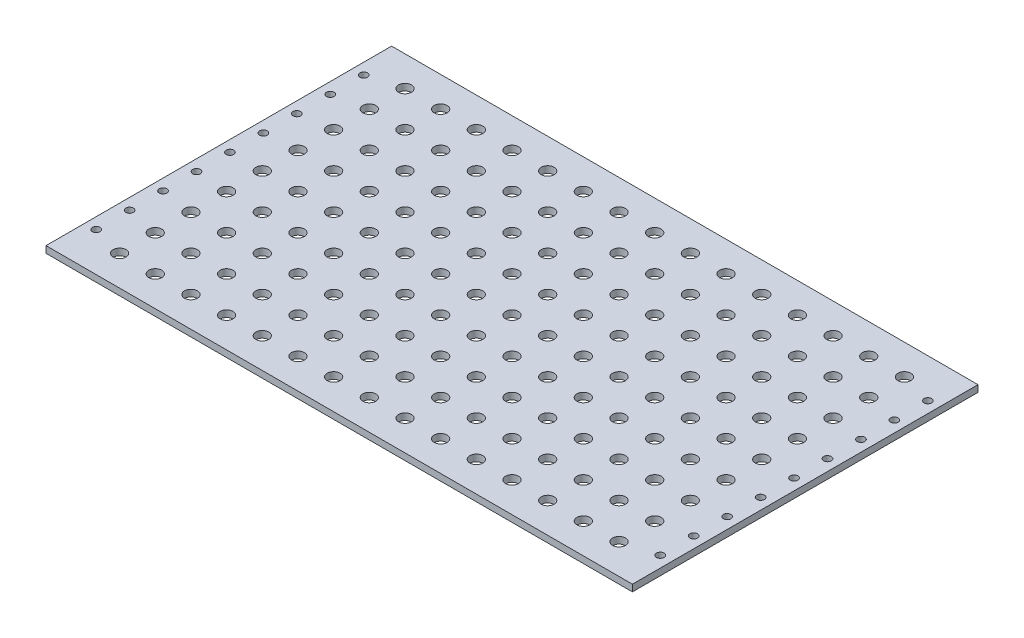
from build123d import *

# Parameters (mm, degrees)
CROQUIS1_W                   = 263
CROQUIS1_H                   = 155
SALIENTE_EXTRUIR1_DEPTH      = 3
TALADRO_DE_MARGEN_PARA_M51_D = 5.8
MATRIZL1_COUNT               = 8
MATRIZL1_PITCH               = 16
MATRIZL1_COUNT_DIR2          = 5
MATRIZL1_PITCH_DIR2          = 16
SIMETR_A1_COPY_1_D           = 5.8
SIMETR_A1_COPY_2_D           = 5.8
SIMETR_A1_COPY_3_D           = 5.8
SIMETR_A1_COPY_4_D           = 5.8
SIMETR_A1_COPY_5_D           = 5.8
SIMETR_A1_COPY_6_D           = 5.8
SIMETR_A1_COPY_7_D           = 5.8
SIMETR_A1_COPY_8_D           = 5.8
SIMETR_A1_COPY_9_D           = 5.8
SIMETR_A1_COPY_10_D          = 5.8
SIMETR_A1_COPY_11_D          = 5.8
SIMETR_A1_COPY_12_D          = 5.8
SIMETR_A1_COPY_13_D          = 5.8
SIMETR_A1_COPY_14_D          = 5.8
SIMETR_A1_COPY_15_D          = 5.8
SIMETR_A1_COPY_16_D          = 5.8
SIMETR_A1_COPY_17_D          = 5.8
SIMETR_A1_COPY_18_D          = 5.8
SIMETR_A1_COPY_19_D          = 5.8
SIMETR_A1_COPY_20_D          = 5.8
SIMETR_A1_COPY_21_D          = 5.8
SIMETR_A1_COPY_22_D          = 5.8
SIMETR_A1_COPY_23_D          = 5.8
SIMETR_A1_COPY_24_D          = 5.8
SIMETR_A1_COPY_25_D          = 5.8
SIMETR_A1_COPY_26_D          = 5.8
SIMETR_A1_COPY_27_D          = 5.8
SIMETR_A1_COPY_28_D          = 5.8
SIMETR_A1_COPY_29_D          = 5.8
SIMETR_A1_COPY_30_D          = 5.8
SIMETR_A1_COPY_31_D          = 5.8
SIMETR_A1_COPY_32_D          = 5.8
SIMETR_A1_COPY_33_D          = 5.8
SIMETR_A1_COPY_34_D          = 5.8
SIMETR_A1_COPY_35_D          = 5.8
SIMETR_A1_COPY_36_D          = 5.8
SIMETR_A1_COPY_37_D          = 5.8
SIMETR_A1_COPY_38_D          = 5.8
SIMETR_A1_COPY_39_D          = 5.8
SIMETR_A1_COPY_40_D          = 5.8
SIMETR_A2_COPY_1_D           = 5.8
SIMETR_A2_COPY_2_D           = 5.8
SIMETR_A2_COPY_3_D           = 5.8
SIMETR_A2_COPY_4_D           = 5.8
SIMETR_A2_COPY_5_D           = 5.8
SIMETR_A2_COPY_6_D           = 5.8
SIMETR_A2_COPY_7_D           = 5.8
SIMETR_A2_COPY_8_D           = 5.8
SIMETR_A2_COPY_9_D           = 5.8
SIMETR_A2_COPY_10_D          = 5.8
SIMETR_A2_COPY_11_D          = 5.8
SIMETR_A2_COPY_12_D          = 5.8
SIMETR_A2_COPY_13_D          = 5.8
SIMETR_A2_COPY_14_D          = 5.8
SIMETR_A2_COPY_15_D          = 5.8
SIMETR_A2_COPY_16_D          = 5.8
SIMETR_A2_COPY_17_D          = 5.8
SIMETR_A2_COPY_18_D          = 5.8
SIMETR_A2_COPY_19_D          = 5.8
SIMETR_A2_COPY_20_D          = 5.8
SIMETR_A2_COPY_21_D          = 5.8
SIMETR_A2_COPY_22_D          = 5.8
SIMETR_A2_COPY_23_D          = 5.8
SIMETR_A2_COPY_24_D          = 5.8
SIMETR_A2_COPY_25_D          = 5.8
SIMETR_A2_COPY_26_D          = 5.8
SIMETR_A2_COPY_27_D          = 5.8
SIMETR_A2_COPY_28_D          = 5.8
SIMETR_A2_COPY_29_D          = 5.8
SIMETR_A2_COPY_30_D          = 5.8
SIMETR_A2_COPY_31_D          = 5.8
SIMETR_A2_COPY_32_D          = 5.8
SIMETR_A2_COPY_33_D          = 5.8
SIMETR_A2_COPY_34_D          = 5.8
SIMETR_A2_COPY_35_D          = 5.8
SIMETR_A2_COPY_36_D          = 5.8
SIMETR_A2_COPY_37_D          = 5.8
SIMETR_A2_COPY_38_D          = 5.8
SIMETR_A2_COPY_39_D          = 5.8
SIMETR_A2_COPY_40_D          = 5.8
SIMETR_A2_COPY_41_D          = 5.8
SIMETR_A2_COPY_42_D          = 5.8
SIMETR_A2_COPY_43_D          = 5.8
SIMETR_A2_COPY_44_D          = 5.8
SIMETR_A2_COPY_45_D          = 5.8
SIMETR_A2_COPY_46_D          = 5.8
SIMETR_A2_COPY_47_D          = 5.8
SIMETR_A2_COPY_48_D          = 5.8
SIMETR_A2_COPY_49_D          = 5.8
SIMETR_A2_COPY_50_D          = 5.8
SIMETR_A2_COPY_51_D          = 5.8
SIMETR_A2_COPY_52_D          = 5.8
SIMETR_A2_COPY_53_D          = 5.8
SIMETR_A2_COPY_54_D          = 5.8
SIMETR_A2_COPY_55_D          = 5.8
SIMETR_A2_COPY_56_D          = 5.8
SIMETR_A2_COPY_57_D          = 5.8
SIMETR_A2_COPY_58_D          = 5.8
SIMETR_A2_COPY_59_D          = 5.8
SIMETR_A2_COPY_60_D          = 5.8
SIMETR_A2_COPY_61_D          = 5.8
SIMETR_A2_COPY_62_D          = 5.8
SIMETR_A2_COPY_63_D          = 5.8
SIMETR_A2_COPY_64_D          = 5.8
SIMETR_A2_COPY_65_D          = 5.8
SIMETR_A2_COPY_66_D          = 5.8
SIMETR_A2_COPY_67_D          = 5.8
SIMETR_A2_COPY_68_D          = 5.8
SIMETR_A2_COPY_69_D          = 5.8
SIMETR_A2_COPY_70_D          = 5.8
SIMETR_A2_COPY_71_D          = 5.8
SIMETR_A2_COPY_72_D          = 5.8
SIMETR_A2_COPY_73_D          = 5.8
SIMETR_A2_COPY_74_D          = 5.8
SIMETR_A2_COPY_75_D          = 5.8
SIMETR_A2_COPY_76_D          = 5.8
SIMETR_A2_COPY_77_D          = 5.8
SIMETR_A2_COPY_78_D          = 5.8
SIMETR_A2_COPY_79_D          = 5.8
SIMETR_A2_COPY_80_D          = 5.8
SIMETR_A2_COPY_81_D          = 5.8
TALADRO_DE_MARGEN_PARA_M31_D = 3.4


with BuildPart() as part:
    # Croquis1 → Saliente-Extruir1 (new body)
    with BuildSketch(Plane(origin=(0, 0, 0), x_dir=(1, 0, 0), z_dir=(0, 1, 0))):
        Rectangle(CROQUIS1_W, CROQUIS1_H)
    extrude(amount=SALIENTE_EXTRUIR1_DEPTH)

    # Taladro de margen para M51 (through all)
    with Locations(Plane(origin=(0, 0, 0), x_dir=(-1, 0, 0), z_dir=(0, -1, 0))):
        with Locations((0, 0)):
            taladro_de_margen_para_m51 = Hole(TALADRO_DE_MARGEN_PARA_M51_D / 2)

    # MatrizL1: Taladro de margen para M51 8 × 5
    with Locations(*[(i * MATRIZL1_PITCH, 0, j * MATRIZL1_PITCH_DIR2) for i in range(MATRIZL1_COUNT) for j in range(MATRIZL1_COUNT_DIR2) if (i, j) != (0, 0)]):
        add(taladro_de_margen_para_m51, mode=Mode.SUBTRACT)

    # Simetría1 copy 1 (through all)
    with Locations(Plane(origin=(0, 0, 16), x_dir=(1, 0, 0), z_dir=(0, -1, 0))):
        with Locations((0, 0)):
            Hole(SIMETR_A1_COPY_1_D / 2)

    # Simetría1 copy 2 (through all)
    with Locations(Plane(origin=(0, 0, 32), x_dir=(1, 0, 0), z_dir=(0, -1, 0))):
        with Locations((0, 0)):
            Hole(SIMETR_A1_COPY_2_D / 2)

    # Simetría1 copy 3 (through all)
    with Locations(Plane(origin=(0, 0, 48), x_dir=(1, 0, 0), z_dir=(0, -1, 0))):
        with Locations((0, 0)):
            Hole(SIMETR_A1_COPY_3_D / 2)

    # Simetría1 copy 4 (through all)
    with Locations(Plane(origin=(0, 0, 64), x_dir=(1, 0, 0), z_dir=(0, -1, 0))):
        with Locations((0, 0)):
            Hole(SIMETR_A1_COPY_4_D / 2)

    # Simetría1 copy 5 (through all)
    with Locations(Plane(origin=(-16, 0, 0), x_dir=(1, 0, 0), z_dir=(0, -1, 0))):
        with Locations((0, 0)):
            Hole(SIMETR_A1_COPY_5_D / 2)

    # Simetría1 copy 6 (through all)
    with Locations(Plane(origin=(-16, 0, 16), x_dir=(1, 0, 0), z_dir=(0, -1, 0))):
        with Locations((0, 0)):
            Hole(SIMETR_A1_COPY_6_D / 2)

    # Simetría1 copy 7 (through all)
    with Locations(Plane(origin=(-16, 0, 32), x_dir=(1, 0, 0), z_dir=(0, -1, 0))):
        with Locations((0, 0)):
            Hole(SIMETR_A1_COPY_7_D / 2)

    # Simetría1 copy 8 (through all)
    with Locations(Plane(origin=(-16, 0, 48), x_dir=(1, 0, 0), z_dir=(0, -1, 0))):
        with Locations((0, 0)):
            Hole(SIMETR_A1_COPY_8_D / 2)

    # Simetría1 copy 9 (through all)
    with Locations(Plane(origin=(-16, 0, 64), x_dir=(1, 0, 0), z_dir=(0, -1, 0))):
        with Locations((0, 0)):
            Hole(SIMETR_A1_COPY_9_D / 2)

    # Simetría1 copy 10 (through all)
    with Locations(Plane(origin=(-32, 0, 0), x_dir=(1, 0, 0), z_dir=(0, -1, 0))):
        with Locations((0, 0)):
            Hole(SIMETR_A1_COPY_10_D / 2)

    # Simetría1 copy 11 (through all)
    with Locations(Plane(origin=(-32, 0, 16), x_dir=(1, 0, 0), z_dir=(0, -1, 0))):
        with Locations((0, 0)):
            Hole(SIMETR_A1_COPY_11_D / 2)

    # Simetría1 copy 12 (through all)
    with Locations(Plane(origin=(-32, 0, 32), x_dir=(1, 0, 0), z_dir=(0, -1, 0))):
        with Locations((0, 0)):
            Hole(SIMETR_A1_COPY_12_D / 2)

    # Simetría1 copy 13 (through all)
    with Locations(Plane(origin=(-32, 0, 48), x_dir=(1, 0, 0), z_dir=(0, -1, 0))):
        with Locations((0, 0)):
            Hole(SIMETR_A1_COPY_13_D / 2)

    # Simetría1 copy 14 (through all)
    with Locations(Plane(origin=(-32, 0, 64), x_dir=(1, 0, 0), z_dir=(0, -1, 0))):
        with Locations((0, 0)):
            Hole(SIMETR_A1_COPY_14_D / 2)

    # Simetría1 copy 15 (through all)
    with Locations(Plane(origin=(-48, 0, 0), x_dir=(1, 0, 0), z_dir=(0, -1, 0))):
        with Locations((0, 0)):
            Hole(SIMETR_A1_COPY_15_D / 2)

    # Simetría1 copy 16 (through all)
    with Locations(Plane(origin=(-48, 0, 16), x_dir=(1, 0, 0), z_dir=(0, -1, 0))):
        with Locations((0, 0)):
            Hole(SIMETR_A1_COPY_16_D / 2)

    # Simetría1 copy 17 (through all)
    with Locations(Plane(origin=(-48, 0, 32), x_dir=(1, 0, 0), z_dir=(0, -1, 0))):
        with Locations((0, 0)):
            Hole(SIMETR_A1_COPY_17_D / 2)

    # Simetría1 copy 18 (through all)
    with Locations(Plane(origin=(-48, 0, 48), x_dir=(1, 0, 0), z_dir=(0, -1, 0))):
        with Locations((0, 0)):
            Hole(SIMETR_A1_COPY_18_D / 2)

    # Simetría1 copy 19 (through all)
    with Locations(Plane(origin=(-48, 0, 64), x_dir=(1, 0, 0), z_dir=(0, -1, 0))):
        with Locations((0, 0)):
            Hole(SIMETR_A1_COPY_19_D / 2)

    # Simetría1 copy 20 (through all)
    with Locations(Plane(origin=(-64, 0, 0), x_dir=(1, 0, 0), z_dir=(0, -1, 0))):
        with Locations((0, 0)):
            Hole(SIMETR_A1_COPY_20_D / 2)

    # Simetría1 copy 21 (through all)
    with Locations(Plane(origin=(-64, 0, 16), x_dir=(1, 0, 0), z_dir=(0, -1, 0))):
        with Locations((0, 0)):
            Hole(SIMETR_A1_COPY_21_D / 2)

    # Simetría1 copy 22 (through all)
    with Locations(Plane(origin=(-64, 0, 32), x_dir=(1, 0, 0), z_dir=(0, -1, 0))):
        with Locations((0, 0)):
            Hole(SIMETR_A1_COPY_22_D / 2)

    # Simetría1 copy 23 (through all)
    with Locations(Plane(origin=(-64, 0, 48), x_dir=(1, 0, 0), z_dir=(0, -1, 0))):
        with Locations((0, 0)):
            Hole(SIMETR_A1_COPY_23_D / 2)

    # Simetría1 copy 24 (through all)
    with Locations(Plane(origin=(-64, 0, 64), x_dir=(1, 0, 0), z_dir=(0, -1, 0))):
        with Locations((0, 0)):
            Hole(SIMETR_A1_COPY_24_D / 2)

    # Simetría1 copy 25 (through all)
    with Locations(Plane(origin=(-80, 0, 0), x_dir=(1, 0, 0), z_dir=(0, -1, 0))):
        with Locations((0, 0)):
            Hole(SIMETR_A1_COPY_25_D / 2)

    # Simetría1 copy 26 (through all)
    with Locations(Plane(origin=(-80, 0, 16), x_dir=(1, 0, 0), z_dir=(0, -1, 0))):
        with Locations((0, 0)):
            Hole(SIMETR_A1_COPY_26_D / 2)

    # Simetría1 copy 27 (through all)
    with Locations(Plane(origin=(-80, 0, 32), x_dir=(1, 0, 0), z_dir=(0, -1, 0))):
        with Locations((0, 0)):
            Hole(SIMETR_A1_COPY_27_D / 2)

    # Simetría1 copy 28 (through all)
    with Locations(Plane(origin=(-80, 0, 48), x_dir=(1, 0, 0), z_dir=(0, -1, 0))):
        with Locations((0, 0)):
            Hole(SIMETR_A1_COPY_28_D / 2)

    # Simetría1 copy 29 (through all)
    with Locations(Plane(origin=(-80, 0, 64), x_dir=(1, 0, 0), z_dir=(0, -1, 0))):
        with Locations((0, 0)):
            Hole(SIMETR_A1_COPY_29_D / 2)

    # Simetría1 copy 30 (through all)
    with Locations(Plane(origin=(-96, 0, 0), x_dir=(1, 0, 0), z_dir=(0, -1, 0))):
        with Locations((0, 0)):
            Hole(SIMETR_A1_COPY_30_D / 2)

    # Simetría1 copy 31 (through all)
    with Locations(Plane(origin=(-96, 0, 16), x_dir=(1, 0, 0), z_dir=(0, -1, 0))):
        with Locations((0, 0)):
            Hole(SIMETR_A1_COPY_31_D / 2)

    # Simetría1 copy 32 (through all)
    with Locations(Plane(origin=(-96, 0, 32), x_dir=(1, 0, 0), z_dir=(0, -1, 0))):
        with Locations((0, 0)):
            Hole(SIMETR_A1_COPY_32_D / 2)

    # Simetría1 copy 33 (through all)
    with Locations(Plane(origin=(-96, 0, 48), x_dir=(1, 0, 0), z_dir=(0, -1, 0))):
        with Locations((0, 0)):
            Hole(SIMETR_A1_COPY_33_D / 2)

    # Simetría1 copy 34 (through all)
    with Locations(Plane(origin=(-96, 0, 64), x_dir=(1, 0, 0), z_dir=(0, -1, 0))):
        with Locations((0, 0)):
            Hole(SIMETR_A1_COPY_34_D / 2)

    # Simetría1 copy 35 (through all)
    with Locations(Plane(origin=(-112, 0, 0), x_dir=(1, 0, 0), z_dir=(0, -1, 0))):
        with Locations((0, 0)):
            Hole(SIMETR_A1_COPY_35_D / 2)

    # Simetría1 copy 36 (through all)
    with Locations(Plane(origin=(-112, 0, 16), x_dir=(1, 0, 0), z_dir=(0, -1, 0))):
        with Locations((0, 0)):
            Hole(SIMETR_A1_COPY_36_D / 2)

    # Simetría1 copy 37 (through all)
    with Locations(Plane(origin=(-112, 0, 32), x_dir=(1, 0, 0), z_dir=(0, -1, 0))):
        with Locations((0, 0)):
            Hole(SIMETR_A1_COPY_37_D / 2)

    # Simetría1 copy 38 (through all)
    with Locations(Plane(origin=(-112, 0, 48), x_dir=(1, 0, 0), z_dir=(0, -1, 0))):
        with Locations((0, 0)):
            Hole(SIMETR_A1_COPY_38_D / 2)

    # Simetría1 copy 39 (through all)
    with Locations(Plane(origin=(-112, 0, 64), x_dir=(1, 0, 0), z_dir=(0, -1, 0))):
        with Locations((0, 0)):
            Hole(SIMETR_A1_COPY_39_D / 2)

    # Simetría1 copy 40 (through all)
    with Locations(Plane.XZ):
        with Locations((0, 0)):
            Hole(SIMETR_A1_COPY_40_D / 2)

    # Simetría2 copy 1 (through all)
    with Locations(Plane(origin=(0, 0, -16), x_dir=(-1, 0, 0), z_dir=(0, -1, 0))):
        with Locations((0, 0)):
            Hole(SIMETR_A2_COPY_1_D / 2)

    # Simetría2 copy 2 (through all)
    with Locations(Plane(origin=(0, 0, -32), x_dir=(-1, 0, 0), z_dir=(0, -1, 0))):
        with Locations((0, 0)):
            Hole(SIMETR_A2_COPY_2_D / 2)

    # Simetría2 copy 3 (through all)
    with Locations(Plane(origin=(0, 0, -48), x_dir=(-1, 0, 0), z_dir=(0, -1, 0))):
        with Locations((0, 0)):
            Hole(SIMETR_A2_COPY_3_D / 2)

    # Simetría2 copy 4 (through all)
    with Locations(Plane(origin=(0, 0, -64), x_dir=(-1, 0, 0), z_dir=(0, -1, 0))):
        with Locations((0, 0)):
            Hole(SIMETR_A2_COPY_4_D / 2)

    # Simetría2 copy 5 (through all)
    with Locations(Plane(origin=(16, 0, 0), x_dir=(-1, 0, 0), z_dir=(0, -1, 0))):
        with Locations((0, 0)):
            Hole(SIMETR_A2_COPY_5_D / 2)

    # Simetría2 copy 6 (through all)
    with Locations(Plane(origin=(16, 0, -16), x_dir=(-1, 0, 0), z_dir=(0, -1, 0))):
        with Locations((0, 0)):
            Hole(SIMETR_A2_COPY_6_D / 2)

    # Simetría2 copy 7 (through all)
    with Locations(Plane(origin=(16, 0, -32), x_dir=(-1, 0, 0), z_dir=(0, -1, 0))):
        with Locations((0, 0)):
            Hole(SIMETR_A2_COPY_7_D / 2)

    # Simetría2 copy 8 (through all)
    with Locations(Plane(origin=(16, 0, -48), x_dir=(-1, 0, 0), z_dir=(0, -1, 0))):
        with Locations((0, 0)):
            Hole(SIMETR_A2_COPY_8_D / 2)

    # Simetría2 copy 9 (through all)
    with Locations(Plane(origin=(16, 0, -64), x_dir=(-1, 0, 0), z_dir=(0, -1, 0))):
        with Locations((0, 0)):
            Hole(SIMETR_A2_COPY_9_D / 2)

    # Simetría2 copy 10 (through all)
    with Locations(Plane(origin=(32, 0, 0), x_dir=(-1, 0, 0), z_dir=(0, -1, 0))):
        with Locations((0, 0)):
            Hole(SIMETR_A2_COPY_10_D / 2)

    # Simetría2 copy 11 (through all)
    with Locations(Plane(origin=(32, 0, -16), x_dir=(-1, 0, 0), z_dir=(0, -1, 0))):
        with Locations((0, 0)):
            Hole(SIMETR_A2_COPY_11_D / 2)

    # Simetría2 copy 12 (through all)
    with Locations(Plane(origin=(32, 0, -32), x_dir=(-1, 0, 0), z_dir=(0, -1, 0))):
        with Locations((0, 0)):
            Hole(SIMETR_A2_COPY_12_D / 2)

    # Simetría2 copy 13 (through all)
    with Locations(Plane(origin=(32, 0, -48), x_dir=(-1, 0, 0), z_dir=(0, -1, 0))):
        with Locations((0, 0)):
            Hole(SIMETR_A2_COPY_13_D / 2)

    # Simetría2 copy 14 (through all)
    with Locations(Plane(origin=(32, 0, -64), x_dir=(-1, 0, 0), z_dir=(0, -1, 0))):
        with Locations((0, 0)):
            Hole(SIMETR_A2_COPY_14_D / 2)

    # Simetría2 copy 15 (through all)
    with Locations(Plane(origin=(48, 0, 0), x_dir=(-1, 0, 0), z_dir=(0, -1, 0))):
        with Locations((0, 0)):
            Hole(SIMETR_A2_COPY_15_D / 2)

    # Simetría2 copy 16 (through all)
    with Locations(Plane(origin=(48, 0, -16), x_dir=(-1, 0, 0), z_dir=(0, -1, 0))):
        with Locations((0, 0)):
            Hole(SIMETR_A2_COPY_16_D / 2)

    # Simetría2 copy 17 (through all)
    with Locations(Plane(origin=(48, 0, -32), x_dir=(-1, 0, 0), z_dir=(0, -1, 0))):
        with Locations((0, 0)):
            Hole(SIMETR_A2_COPY_17_D / 2)

    # Simetría2 copy 18 (through all)
    with Locations(Plane(origin=(48, 0, -48), x_dir=(-1, 0, 0), z_dir=(0, -1, 0))):
        with Locations((0, 0)):
            Hole(SIMETR_A2_COPY_18_D / 2)

    # Simetría2 copy 19 (through all)
    with Locations(Plane(origin=(48, 0, -64), x_dir=(-1, 0, 0), z_dir=(0, -1, 0))):
        with Locations((0, 0)):
            Hole(SIMETR_A2_COPY_19_D / 2)

    # Simetría2 copy 20 (through all)
    with Locations(Plane(origin=(64, 0, 0), x_dir=(-1, 0, 0), z_dir=(0, -1, 0))):
        with Locations((0, 0)):
            Hole(SIMETR_A2_COPY_20_D / 2)

    # Simetría2 copy 21 (through all)
    with Locations(Plane(origin=(64, 0, -16), x_dir=(-1, 0, 0), z_dir=(0, -1, 0))):
        with Locations((0, 0)):
            Hole(SIMETR_A2_COPY_21_D / 2)

    # Simetría2 copy 22 (through all)
    with Locations(Plane(origin=(64, 0, -32), x_dir=(-1, 0, 0), z_dir=(0, -1, 0))):
        with Locations((0, 0)):
            Hole(SIMETR_A2_COPY_22_D / 2)

    # Simetría2 copy 23 (through all)
    with Locations(Plane(origin=(64, 0, -48), x_dir=(-1, 0, 0), z_dir=(0, -1, 0))):
        with Locations((0, 0)):
            Hole(SIMETR_A2_COPY_23_D / 2)

    # Simetría2 copy 24 (through all)
    with Locations(Plane(origin=(64, 0, -64), x_dir=(-1, 0, 0), z_dir=(0, -1, 0))):
        with Locations((0, 0)):
            Hole(SIMETR_A2_COPY_24_D / 2)

    # Simetría2 copy 25 (through all)
    with Locations(Plane(origin=(80, 0, 0), x_dir=(-1, 0, 0), z_dir=(0, -1, 0))):
        with Locations((0, 0)):
            Hole(SIMETR_A2_COPY_25_D / 2)

    # Simetría2 copy 26 (through all)
    with Locations(Plane(origin=(80, 0, -16), x_dir=(-1, 0, 0), z_dir=(0, -1, 0))):
        with Locations((0, 0)):
            Hole(SIMETR_A2_COPY_26_D / 2)

    # Simetría2 copy 27 (through all)
    with Locations(Plane(origin=(80, 0, -32), x_dir=(-1, 0, 0), z_dir=(0, -1, 0))):
        with Locations((0, 0)):
            Hole(SIMETR_A2_COPY_27_D / 2)

    # Simetría2 copy 28 (through all)
    with Locations(Plane(origin=(80, 0, -48), x_dir=(-1, 0, 0), z_dir=(0, -1, 0))):
        with Locations((0, 0)):
            Hole(SIMETR_A2_COPY_28_D / 2)

    # Simetría2 copy 29 (through all)
    with Locations(Plane(origin=(80, 0, -64), x_dir=(-1, 0, 0), z_dir=(0, -1, 0))):
        with Locations((0, 0)):
            Hole(SIMETR_A2_COPY_29_D / 2)

    # Simetría2 copy 30 (through all)
    with Locations(Plane(origin=(96, 0, 0), x_dir=(-1, 0, 0), z_dir=(0, -1, 0))):
        with Locations((0, 0)):
            Hole(SIMETR_A2_COPY_30_D / 2)

    # Simetría2 copy 31 (through all)
    with Locations(Plane(origin=(96, 0, -16), x_dir=(-1, 0, 0), z_dir=(0, -1, 0))):
        with Locations((0, 0)):
            Hole(SIMETR_A2_COPY_31_D / 2)

    # Simetría2 copy 32 (through all)
    with Locations(Plane(origin=(96, 0, -32), x_dir=(-1, 0, 0), z_dir=(0, -1, 0))):
        with Locations((0, 0)):
            Hole(SIMETR_A2_COPY_32_D / 2)

    # Simetría2 copy 33 (through all)
    with Locations(Plane(origin=(96, 0, -48), x_dir=(-1, 0, 0), z_dir=(0, -1, 0))):
        with Locations((0, 0)):
            Hole(SIMETR_A2_COPY_33_D / 2)

    # Simetría2 copy 34 (through all)
    with Locations(Plane(origin=(96, 0, -64), x_dir=(-1, 0, 0), z_dir=(0, -1, 0))):
        with Locations((0, 0)):
            Hole(SIMETR_A2_COPY_34_D / 2)

    # Simetría2 copy 35 (through all)
    with Locations(Plane(origin=(112, 0, 0), x_dir=(-1, 0, 0), z_dir=(0, -1, 0))):
        with Locations((0, 0)):
            Hole(SIMETR_A2_COPY_35_D / 2)

    # Simetría2 copy 36 (through all)
    with Locations(Plane(origin=(112, 0, -16), x_dir=(-1, 0, 0), z_dir=(0, -1, 0))):
        with Locations((0, 0)):
            Hole(SIMETR_A2_COPY_36_D / 2)

    # Simetría2 copy 37 (through all)
    with Locations(Plane(origin=(112, 0, -32), x_dir=(-1, 0, 0), z_dir=(0, -1, 0))):
        with Locations((0, 0)):
            Hole(SIMETR_A2_COPY_37_D / 2)

    # Simetría2 copy 38 (through all)
    with Locations(Plane(origin=(112, 0, -48), x_dir=(-1, 0, 0), z_dir=(0, -1, 0))):
        with Locations((0, 0)):
            Hole(SIMETR_A2_COPY_38_D / 2)

    # Simetría2 copy 39 (through all)
    with Locations(Plane(origin=(112, 0, -64), x_dir=(-1, 0, 0), z_dir=(0, -1, 0))):
        with Locations((0, 0)):
            Hole(SIMETR_A2_COPY_39_D / 2)

    # Simetría2 copy 40 (through all)
    with Locations(Plane(origin=(0, 0, 0), x_dir=(-1, 0, 0), z_dir=(0, -1, 0))):
        with Locations((0, 0)):
            Hole(SIMETR_A2_COPY_40_D / 2)

    # Simetría2 copy 41 (through all)
    with Locations(Plane(origin=(0, 0, -16), x_dir=(1, 0, 0), z_dir=(0, -1, 0))):
        with Locations((0, 0)):
            Hole(SIMETR_A2_COPY_41_D / 2)

    # Simetría2 copy 42 (through all)
    with Locations(Plane(origin=(0, 0, -32), x_dir=(1, 0, 0), z_dir=(0, -1, 0))):
        with Locations((0, 0)):
            Hole(SIMETR_A2_COPY_42_D / 2)

    # Simetría2 copy 43 (through all)
    with Locations(Plane(origin=(0, 0, -48), x_dir=(1, 0, 0), z_dir=(0, -1, 0))):
        with Locations((0, 0)):
            Hole(SIMETR_A2_COPY_43_D / 2)

    # Simetría2 copy 44 (through all)
    with Locations(Plane(origin=(0, 0, -64), x_dir=(1, 0, 0), z_dir=(0, -1, 0))):
        with Locations((0, 0)):
            Hole(SIMETR_A2_COPY_44_D / 2)

    # Simetría2 copy 45 (through all)
    with Locations(Plane(origin=(-16, 0, 0), x_dir=(1, 0, 0), z_dir=(0, -1, 0))):
        with Locations((0, 0)):
            Hole(SIMETR_A2_COPY_45_D / 2)

    # Simetría2 copy 46 (through all)
    with Locations(Plane(origin=(-16, 0, -16), x_dir=(1, 0, 0), z_dir=(0, -1, 0))):
        with Locations((0, 0)):
            Hole(SIMETR_A2_COPY_46_D / 2)

    # Simetría2 copy 47 (through all)
    with Locations(Plane(origin=(-16, 0, -32), x_dir=(1, 0, 0), z_dir=(0, -1, 0))):
        with Locations((0, 0)):
            Hole(SIMETR_A2_COPY_47_D / 2)

    # Simetría2 copy 48 (through all)
    with Locations(Plane(origin=(-16, 0, -48), x_dir=(1, 0, 0), z_dir=(0, -1, 0))):
        with Locations((0, 0)):
            Hole(SIMETR_A2_COPY_48_D / 2)

    # Simetría2 copy 49 (through all)
    with Locations(Plane(origin=(-16, 0, -64), x_dir=(1, 0, 0), z_dir=(0, -1, 0))):
        with Locations((0, 0)):
            Hole(SIMETR_A2_COPY_49_D / 2)

    # Simetría2 copy 50 (through all)
    with Locations(Plane(origin=(-32, 0, 0), x_dir=(1, 0, 0), z_dir=(0, -1, 0))):
        with Locations((0, 0)):
            Hole(SIMETR_A2_COPY_50_D / 2)

    # Simetría2 copy 51 (through all)
    with Locations(Plane(origin=(-32, 0, -16), x_dir=(1, 0, 0), z_dir=(0, -1, 0))):
        with Locations((0, 0)):
            Hole(SIMETR_A2_COPY_51_D / 2)

    # Simetría2 copy 52 (through all)
    with Locations(Plane(origin=(-32, 0, -32), x_dir=(1, 0, 0), z_dir=(0, -1, 0))):
        with Locations((0, 0)):
            Hole(SIMETR_A2_COPY_52_D / 2)

    # Simetría2 copy 53 (through all)
    with Locations(Plane(origin=(-32, 0, -48), x_dir=(1, 0, 0), z_dir=(0, -1, 0))):
        with Locations((0, 0)):
            Hole(SIMETR_A2_COPY_53_D / 2)

    # Simetría2 copy 54 (through all)
    with Locations(Plane(origin=(-32, 0, -64), x_dir=(1, 0, 0), z_dir=(0, -1, 0))):
        with Locations((0, 0)):
            Hole(SIMETR_A2_COPY_54_D / 2)

    # Simetría2 copy 55 (through all)
    with Locations(Plane(origin=(-48, 0, 0), x_dir=(1, 0, 0), z_dir=(0, -1, 0))):
        with Locations((0, 0)):
            Hole(SIMETR_A2_COPY_55_D / 2)

    # Simetría2 copy 56 (through all)
    with Locations(Plane(origin=(-48, 0, -16), x_dir=(1, 0, 0), z_dir=(0, -1, 0))):
        with Locations((0, 0)):
            Hole(SIMETR_A2_COPY_56_D / 2)

    # Simetría2 copy 57 (through all)
    with Locations(Plane(origin=(-48, 0, -32), x_dir=(1, 0, 0), z_dir=(0, -1, 0))):
        with Locations((0, 0)):
            Hole(SIMETR_A2_COPY_57_D / 2)

    # Simetría2 copy 58 (through all)
    with Locations(Plane(origin=(-48, 0, -48), x_dir=(1, 0, 0), z_dir=(0, -1, 0))):
        with Locations((0, 0)):
            Hole(SIMETR_A2_COPY_58_D / 2)

    # Simetría2 copy 59 (through all)
    with Locations(Plane(origin=(-48, 0, -64), x_dir=(1, 0, 0), z_dir=(0, -1, 0))):
        with Locations((0, 0)):
            Hole(SIMETR_A2_COPY_59_D / 2)

    # Simetría2 copy 60 (through all)
    with Locations(Plane(origin=(-64, 0, 0), x_dir=(1, 0, 0), z_dir=(0, -1, 0))):
        with Locations((0, 0)):
            Hole(SIMETR_A2_COPY_60_D / 2)

    # Simetría2 copy 61 (through all)
    with Locations(Plane(origin=(-64, 0, -16), x_dir=(1, 0, 0), z_dir=(0, -1, 0))):
        with Locations((0, 0)):
            Hole(SIMETR_A2_COPY_61_D / 2)

    # Simetría2 copy 62 (through all)
    with Locations(Plane(origin=(-64, 0, -32), x_dir=(1, 0, 0), z_dir=(0, -1, 0))):
        with Locations((0, 0)):
            Hole(SIMETR_A2_COPY_62_D / 2)

    # Simetría2 copy 63 (through all)
    with Locations(Plane(origin=(-64, 0, -48), x_dir=(1, 0, 0), z_dir=(0, -1, 0))):
        with Locations((0, 0)):
            Hole(SIMETR_A2_COPY_63_D / 2)

    # Simetría2 copy 64 (through all)
    with Locations(Plane(origin=(-64, 0, -64), x_dir=(1, 0, 0), z_dir=(0, -1, 0))):
        with Locations((0, 0)):
            Hole(SIMETR_A2_COPY_64_D / 2)

    # Simetría2 copy 65 (through all)
    with Locations(Plane(origin=(-80, 0, 0), x_dir=(1, 0, 0), z_dir=(0, -1, 0))):
        with Locations((0, 0)):
            Hole(SIMETR_A2_COPY_65_D / 2)

    # Simetría2 copy 66 (through all)
    with Locations(Plane(origin=(-80, 0, -16), x_dir=(1, 0, 0), z_dir=(0, -1, 0))):
        with Locations((0, 0)):
            Hole(SIMETR_A2_COPY_66_D / 2)

    # Simetría2 copy 67 (through all)
    with Locations(Plane(origin=(-80, 0, -32), x_dir=(1, 0, 0), z_dir=(0, -1, 0))):
        with Locations((0, 0)):
            Hole(SIMETR_A2_COPY_67_D / 2)

    # Simetría2 copy 68 (through all)
    with Locations(Plane(origin=(-80, 0, -48), x_dir=(1, 0, 0), z_dir=(0, -1, 0))):
        with Locations((0, 0)):
            Hole(SIMETR_A2_COPY_68_D / 2)

    # Simetría2 copy 69 (through all)
    with Locations(Plane(origin=(-80, 0, -64), x_dir=(1, 0, 0), z_dir=(0, -1, 0))):
        with Locations((0, 0)):
            Hole(SIMETR_A2_COPY_69_D / 2)

    # Simetría2 copy 70 (through all)
    with Locations(Plane(origin=(-96, 0, 0), x_dir=(1, 0, 0), z_dir=(0, -1, 0))):
        with Locations((0, 0)):
            Hole(SIMETR_A2_COPY_70_D / 2)

    # Simetría2 copy 71 (through all)
    with Locations(Plane(origin=(-96, 0, -16), x_dir=(1, 0, 0), z_dir=(0, -1, 0))):
        with Locations((0, 0)):
            Hole(SIMETR_A2_COPY_71_D / 2)

    # Simetría2 copy 72 (through all)
    with Locations(Plane(origin=(-96, 0, -32), x_dir=(1, 0, 0), z_dir=(0, -1, 0))):
        with Locations((0, 0)):
            Hole(SIMETR_A2_COPY_72_D / 2)

    # Simetría2 copy 73 (through all)
    with Locations(Plane(origin=(-96, 0, -48), x_dir=(1, 0, 0), z_dir=(0, -1, 0))):
        with Locations((0, 0)):
            Hole(SIMETR_A2_COPY_73_D / 2)

    # Simetría2 copy 74 (through all)
    with Locations(Plane(origin=(-96, 0, -64), x_dir=(1, 0, 0), z_dir=(0, -1, 0))):
        with Locations((0, 0)):
            Hole(SIMETR_A2_COPY_74_D / 2)

    # Simetría2 copy 75 (through all)
    with Locations(Plane(origin=(-112, 0, 0), x_dir=(1, 0, 0), z_dir=(0, -1, 0))):
        with Locations((0, 0)):
            Hole(SIMETR_A2_COPY_75_D / 2)

    # Simetría2 copy 76 (through all)
    with Locations(Plane(origin=(-112, 0, -16), x_dir=(1, 0, 0), z_dir=(0, -1, 0))):
        with Locations((0, 0)):
            Hole(SIMETR_A2_COPY_76_D / 2)

    # Simetría2 copy 77 (through all)
    with Locations(Plane(origin=(-112, 0, -32), x_dir=(1, 0, 0), z_dir=(0, -1, 0))):
        with Locations((0, 0)):
            Hole(SIMETR_A2_COPY_77_D / 2)

    # Simetría2 copy 78 (through all)
    with Locations(Plane(origin=(-112, 0, -48), x_dir=(1, 0, 0), z_dir=(0, -1, 0))):
        with Locations((0, 0)):
            Hole(SIMETR_A2_COPY_78_D / 2)

    # Simetría2 copy 79 (through all)
    with Locations(Plane(origin=(-112, 0, -64), x_dir=(1, 0, 0), z_dir=(0, -1, 0))):
        with Locations((0, 0)):
            Hole(SIMETR_A2_COPY_79_D / 2)

    # Simetría2 copy 80 (through all)
    with Locations(Plane.XZ):
        with Locations((0, 0)):
            Hole(SIMETR_A2_COPY_80_D / 2)

    # Simetría2 copy 81 (through all)
    with Locations(Plane(origin=(0, 0, 0), x_dir=(-1, 0, 0), z_dir=(0, -1, 0))):
        with Locations((0, 0)):
            Hole(SIMETR_A2_COPY_81_D / 2)

    # Taladro de margen para M31 (through all)
    with Locations(Plane(origin=(0, 0, 0), x_dir=(-1, 0, 0), z_dir=(0, -1, 0))):
        with Locations((-126.5, 60), (-126.5, 45), (-126.5, 30), (-126.5, 15), (-126.5, 0), (-126.5, -15), (-126.5, -30), (-126.5, -45), (-126.5, -60)):
            taladro_de_margen_para_m31 = Hole(TALADRO_DE_MARGEN_PARA_M31_D / 2)

    # Simetría3: Taladro de margen para M31 across plane
    add(taladro_de_margen_para_m31.mirror(Plane(origin=(0, 0, 0), x_dir=(0, 0, 1), z_dir=(1, 0, 0))), mode=Mode.SUBTRACT)


solid = part.part
